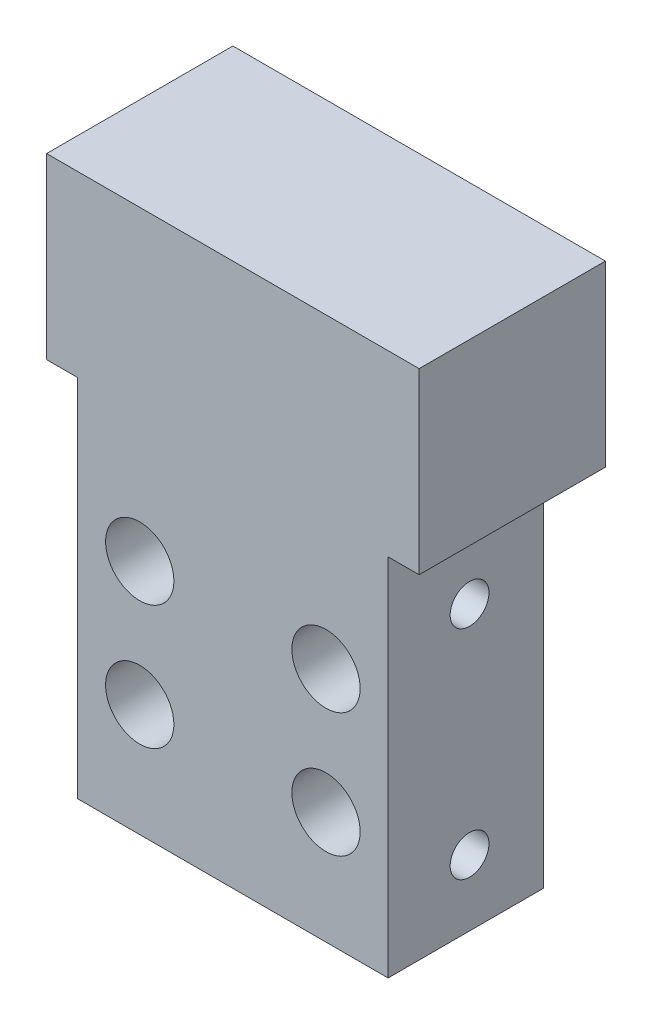
from build123d import *

# Parameters (mm, degrees)
SKETCH1_W                       = 20
SKETCH1_H                       = 22.5
BOSS_EXTRUDE1_DEPTH             = 10
CBORE_FOR_M2_SHCS1_D            = 2.4
CBORE_FOR_M2_SHCS1_CBORE_D      = 4.4
CBORE_FOR_M2_SHCS1_CBORE_DEPTH  = 4
SKETCH4_W                       = 24
SKETCH4_H                       = 12
BOSS_EXTRUDE2_DEPTH             = 12.5
TAP_DRILL_FOR_M3X0_5_TAP1_D     = 2.5
TAP_DRILL_FOR_M3X0_5_TAP1_DEPTH = 4
TAP_DRILL_FOR_M3X0_5_TAP1_TIP   = 0.751075774
TAP_DRILL_FOR_M3X0_5_TAP2_D     = 2.5
TAP_DRILL_FOR_M3X0_5_TAP2_DEPTH = 4
TAP_DRILL_FOR_M3X0_5_TAP2_TIP   = 0.751075774
CUT_EXTRUDE1_DEPTH              = 1


with BuildPart() as part:
    # Sketch1 → Boss-Extrude1 (new body)
    with BuildSketch(Plane.XY):
        with Locations((10, 11.25)):
            Rectangle(SKETCH1_W, SKETCH1_H)
    extrude(amount=BOSS_EXTRUDE1_DEPTH)

    # CBORE for M2 SHCS1 (through all)
    with Locations(Plane.XY.offset(10)):
        with Locations((4, 15.25), (16, 15.25), (16, 7.25), (4, 7.25)):
            CounterBoreHole(CBORE_FOR_M2_SHCS1_D / 2, CBORE_FOR_M2_SHCS1_CBORE_D / 2, CBORE_FOR_M2_SHCS1_CBORE_DEPTH)

    # Sketch4 → Boss-Extrude2 (add)
    with BuildSketch(Plane(origin=(0, 22.5, 0), x_dir=(1, 0, 0), z_dir=(0, 1, 0))):
        with Locations((10, -4)):
            Rectangle(SKETCH4_W, SKETCH4_H)
    extrude(amount=BOSS_EXTRUDE2_DEPTH)

    # Tap Drill for M3x0.5 Tap1
    with Locations(Plane(origin=(20, 0, 0), x_dir=(0, 0, -1), z_dir=(1, 0, 0))):
        with Locations((-4.751843682, 18.25), (-4.751843682, 4.25)):
            Hole(TAP_DRILL_FOR_M3X0_5_TAP1_D / 2, depth=TAP_DRILL_FOR_M3X0_5_TAP1_DEPTH)
            with Locations((0, 0, -(TAP_DRILL_FOR_M3X0_5_TAP1_DEPTH + TAP_DRILL_FOR_M3X0_5_TAP1_TIP / 2))):  # 118° drill point
                Cone(0, TAP_DRILL_FOR_M3X0_5_TAP1_D / 2, TAP_DRILL_FOR_M3X0_5_TAP1_TIP, mode=Mode.SUBTRACT)

    # Tap Drill for M3x0.5 Tap2
    with Locations(Plane.ZY):
        with Locations((4.751843682, 18.25), (4.751843682, 4.25)):
            Hole(TAP_DRILL_FOR_M3X0_5_TAP2_D / 2, depth=TAP_DRILL_FOR_M3X0_5_TAP2_DEPTH)
            with Locations((0, 0, -(TAP_DRILL_FOR_M3X0_5_TAP2_DEPTH + TAP_DRILL_FOR_M3X0_5_TAP2_TIP / 2))):  # 118° drill point
                Cone(0, TAP_DRILL_FOR_M3X0_5_TAP2_D / 2, TAP_DRILL_FOR_M3X0_5_TAP2_TIP, mode=Mode.SUBTRACT)

    # Sketch9 → Cut-Extrude1 (cut)
    with BuildSketch(Plane.XZ.offset(-22.5)):
        Polygon((0, 0), (0, 10), (-2, 10), (-2, -2), (22, -2), (22, 10), (20, 10), (20, 0), align=None)
    extrude(amount=-CUT_EXTRUDE1_DEPTH, mode=Mode.SUBTRACT)


solid = part.part
